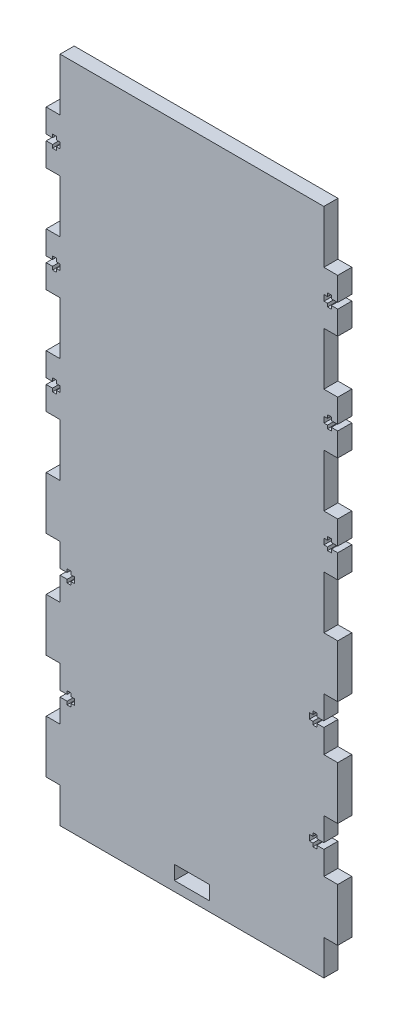
from build123d import *

# Parameters (mm, degrees)
SKETCH1_W           = 150
SKETCH1_H           = 380
SKETCH1_W_2         = 20
SKETCH1_H_2         = 8
BOSS_EXTRUDE1_DEPTH = 8
SKETCH2_W           = 7.9
SKETCH2_H           = 30
BOSS_EXTRUDE2_DEPTH = 8
CUT_EXTRUDE2_DEPTH  = 9


with BuildPart() as part:
    # Sketch1 → Boss-Extrude1 (new body)
    with BuildSketch(Plane.XY):
        with Locations((75, 190)):
            Rectangle(SKETCH1_W, SKETCH1_H)
        with Locations((75, 9.5)):
            Rectangle(SKETCH1_W_2, SKETCH1_H_2, mode=Mode.SUBTRACT)
    extrude(amount=BOSS_EXTRUDE1_DEPTH)

    # Sketch2 → Boss-Extrude2 (add)
    with BuildSketch(Plane.XY.offset(8)):
        with Locations((153.95, 335)):
            Rectangle(SKETCH2_W, SKETCH2_H)
        with Locations((-3.95, 335)):
            Rectangle(SKETCH2_W, SKETCH2_H)
        with Locations((153.95, 275)):
            Rectangle(SKETCH2_W, SKETCH2_H)
        with Locations((-3.95, 275)):
            Rectangle(SKETCH2_W, SKETCH2_H)
        with Locations((153.95, 215)):
            Rectangle(SKETCH2_W, SKETCH2_H)
        with Locations((-3.95, 215)):
            Rectangle(SKETCH2_W, SKETCH2_H)
        with Locations((153.95, 155)):
            Rectangle(SKETCH2_W, SKETCH2_H)
        with Locations((-3.95, 155)):
            Rectangle(SKETCH2_W, SKETCH2_H)
        with Locations((153.95, 95)):
            Rectangle(SKETCH2_W, SKETCH2_H)
        with Locations((-3.95, 95)):
            Rectangle(SKETCH2_W, SKETCH2_H)
        with Locations((153.95, 35)):
            Rectangle(SKETCH2_W, SKETCH2_H)
        with Locations((-3.95, 35)):
            Rectangle(SKETCH2_W, SKETCH2_H)
    extrude(amount=-BOSS_EXTRUDE2_DEPTH)

    # Sketch3 → Cut-Extrude2 (cut, through all)
    with BuildSketch(Plane(origin=(0, 0, 0), x_dir=(-1, 0, 0), z_dir=(0, 0, -1))):
        Polygon((7.9, 273.35), (7.9, 276.65), (4.3, 276.65), (4.3, 278.5), (2.1, 278.5), (2.1, 276.65), (0.1, 276.65), (0.1, 273.35), (2.1, 273.35), (2.1, 271.5), (4.3, 271.5), (4.3, 273.35), align=None)
        Polygon((7.9, 333.35), (7.9, 336.65), (4.3, 336.65), (4.3, 338.5), (2.1, 338.5), (2.1, 336.65), (0.1, 336.65), (0.1, 333.35), (2.1, 333.35), (2.1, 331.5), (4.3, 331.5), (4.3, 333.35), align=None)
        Polygon((7.9, 213.35), (7.9, 216.65), (4.3, 216.65), (4.3, 218.5), (2.1, 218.5), (2.1, 216.65), (0.1, 216.65), (0.1, 213.35), (2.1, 213.35), (2.1, 211.5), (4.3, 211.5), (4.3, 213.35), align=None)
        Polygon((-157.9, 213.35), (-154.3, 213.35), (-154.3, 211.5), (-152.1, 211.5), (-152.1, 213.35), (-150.1, 213.35), (-150.1, 216.65), (-152.1, 216.65), (-152.1, 218.5), (-154.3, 218.5), (-154.3, 216.65), (-157.9, 216.65), align=None)
        Polygon((-157.9, 273.35), (-154.3, 273.35), (-154.3, 271.5), (-152.1, 271.5), (-152.1, 273.35), (-150.1, 273.35), (-150.1, 276.65), (-152.1, 276.65), (-152.1, 278.5), (-154.3, 278.5), (-154.3, 276.65), (-157.9, 276.65), align=None)
        Polygon((-157.9, 333.35), (-154.3, 333.35), (-154.3, 331.5), (-152.1, 331.5), (-152.1, 333.35), (-150.1, 333.35), (-150.1, 336.65), (-152.1, 336.65), (-152.1, 338.5), (-154.3, 338.5), (-154.3, 336.65), (-157.9, 336.65), align=None)
        Polygon((0, 123.35), (0, 126.65), (-4, 126.65), (-4, 128.5), (-6.2, 128.5), (-6.2, 126.65), (-8.2, 126.65), (-8.2, 123.35), (-6.2, 123.35), (-6.2, 121.5), (-4, 121.5), (-4, 123.35), align=None)
        Polygon((0, 63.35), (0, 66.65), (-4, 66.65), (-4, 68.5), (-6.2, 68.5), (-6.2, 66.65), (-8.2, 66.65), (-8.2, 63.35), (-6.2, 63.35), (-6.2, 61.5), (-4, 61.5), (-4, 63.35), align=None)
        Polygon((-150, 63.35), (-146, 63.35), (-146, 61.5), (-143.8, 61.5), (-143.8, 63.35), (-141.8, 63.35), (-141.8, 66.65), (-143.8, 66.65), (-143.8, 68.5), (-146, 68.5), (-146, 66.65), (-150, 66.65), align=None)
        Polygon((-150, 123.35), (-146, 123.35), (-146, 121.5), (-143.8, 121.5), (-143.8, 123.35), (-141.8, 123.35), (-141.8, 126.65), (-143.8, 126.65), (-143.8, 128.5), (-146, 128.5), (-146, 126.65), (-150, 126.65), align=None)
    extrude(amount=-CUT_EXTRUDE2_DEPTH, mode=Mode.SUBTRACT)


solid = part.part
